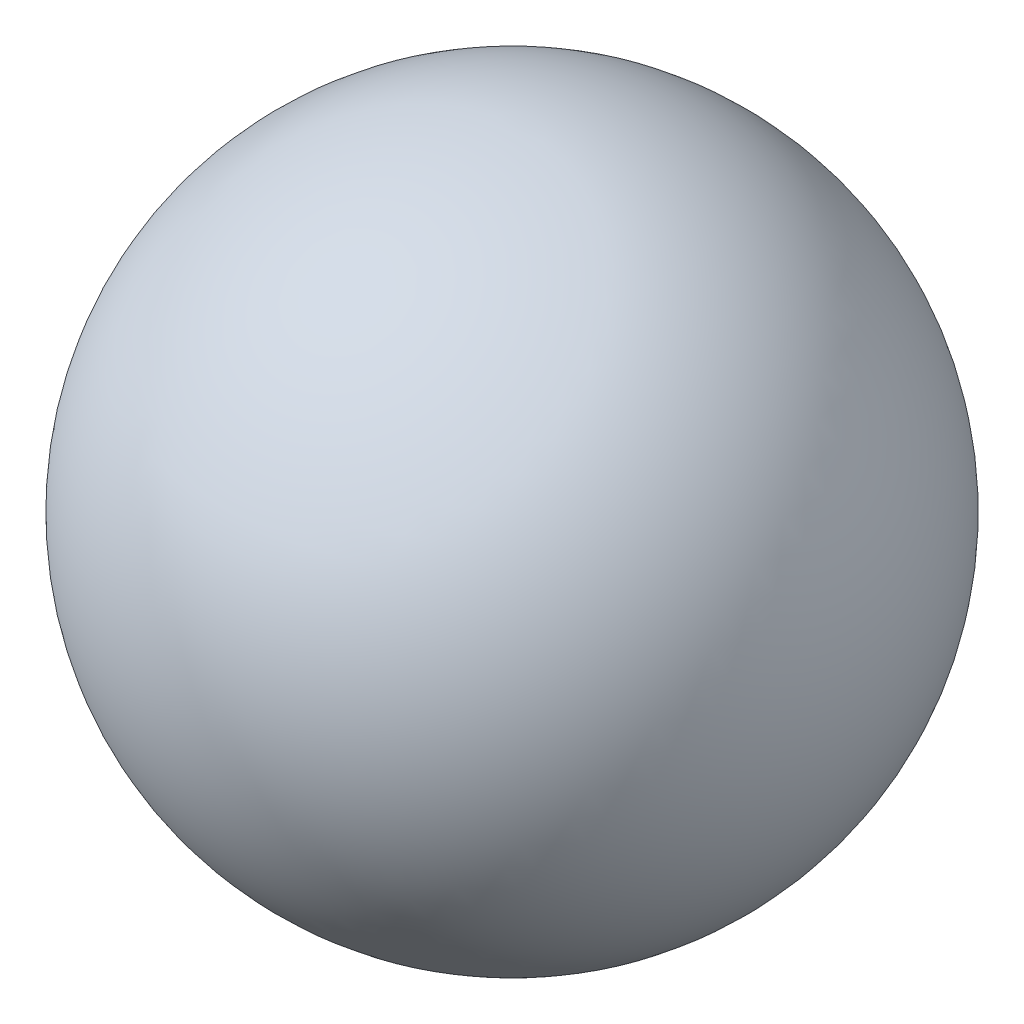
from build123d import *


with BuildPart() as part:
    # Sketch1 → Revolve1 (revolve)
    with BuildSketch(Plane.XY):
        with BuildLine():
            Line((0, 32.5), (0, -32.5))
            ThreePointArc((0, -32.5), (-32.5, 0), (0, 32.5))
        make_face()
    revolve(axis=Axis((0, 32.5, 0), (0, -1, 0)))


solid = part.part
